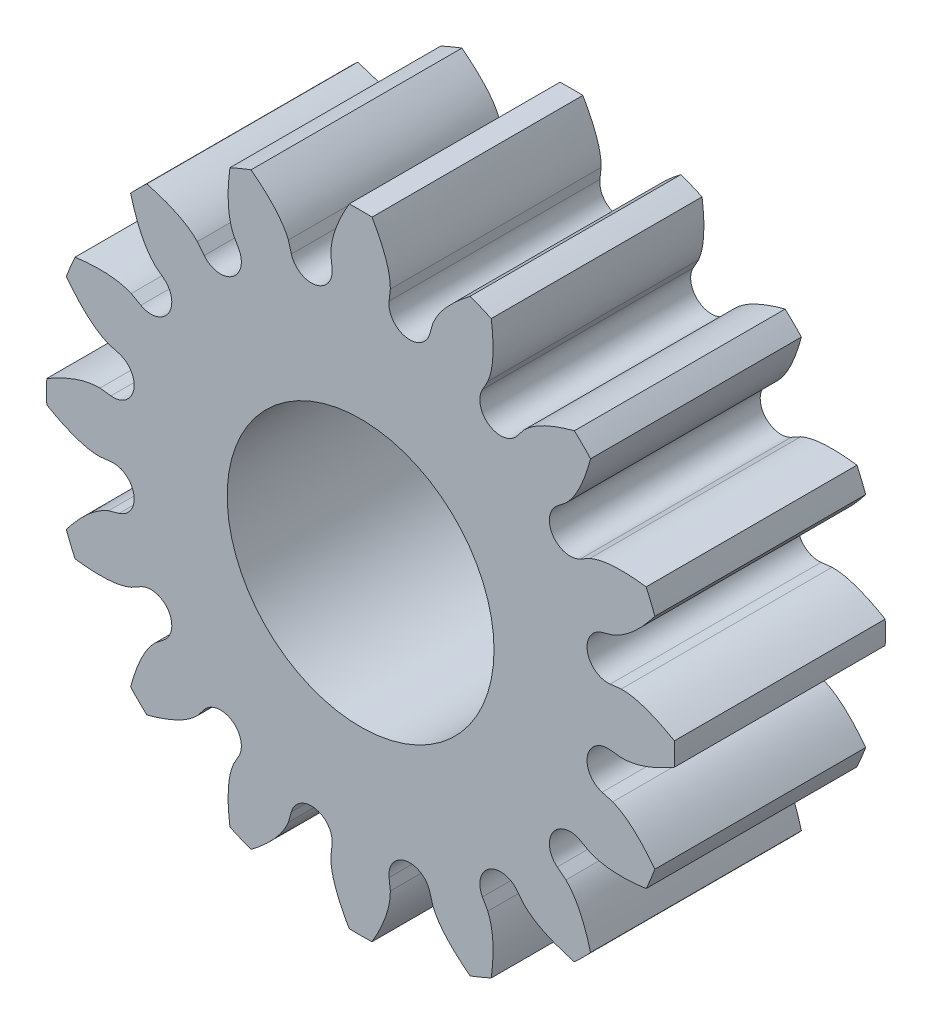
from build123d import *

# Parameters (mm, degrees)
SKETCH3_R                      = 3.302
SKETCH3_R_2                    = 1.905
BASE_DEPTH                     = 3.0099
HALF_TOOTH_DEPTH               = 3.0099
PATTERN_OF_TOOTH_COUNT         = 16
PATTERN_OF_TOOTH_COPY_1_DEPTH  = 3.0099
PATTERN_OF_TOOTH_COPY_2_DEPTH  = 3.0099
PATTERN_OF_TOOTH_COPY_3_DEPTH  = 3.0099
PATTERN_OF_TOOTH_COPY_4_DEPTH  = 3.0099
PATTERN_OF_TOOTH_COPY_5_DEPTH  = 3.0099
PATTERN_OF_TOOTH_COPY_6_DEPTH  = 3.0099
PATTERN_OF_TOOTH_COPY_7_DEPTH  = 3.0099
PATTERN_OF_TOOTH_COPY_8_DEPTH  = 3.0099
PATTERN_OF_TOOTH_COPY_9_DEPTH  = 3.0099
PATTERN_OF_TOOTH_COPY_10_DEPTH = 3.0099
PATTERN_OF_TOOTH_COPY_11_DEPTH = 3.0099
PATTERN_OF_TOOTH_COPY_12_DEPTH = 3.0099
PATTERN_OF_TOOTH_COPY_13_DEPTH = 3.0099
PATTERN_OF_TOOTH_COPY_14_DEPTH = 3.0099
PATTERN_OF_TOOTH_COPY_15_DEPTH = 3.0099


with BuildPart() as part:
    # Sketch3 → Base (new body)
    with BuildSketch(Plane.XY):
        Circle(SKETCH3_R)
        Circle(SKETCH3_R_2, mode=Mode.SUBTRACT)
    extrude(amount=BASE_DEPTH)

    # Sketch2 → Half tooth (add)
    with BuildSketch(Plane.XY):
        with BuildLine():
            Line((0, 4.4831), (0, 3.302))
            ThreePointArc((0, 3.302), (0.323652597, 3.286099967), (0.644188243, 3.238552996))
            ThreePointArc((0.644188243, 3.238552996), (0.461967142, 3.354931937), (0.406719024, 3.563968377))
            Line((0.406719024, 3.563968377), (0.424583044, 3.720505934))
            add(Edge.make_bspline(
                [(0.424583044, 3.720505934), (0.425845761, 3.803383511), (0.380146027, 4.07262239), (0.256625132, 4.316784142), (0.163284713, 4.480125413)],
                knots=[0, 0, 0, 0, 0.305960693, 1, 1, 1, 1], degree=3))
            ThreePointArc((0.163284713, 4.480125413), (0.081655902, 4.482356291), (0, 4.4831))
        make_face()
    half_tooth = extrude(amount=HALF_TOOTH_DEPTH)

    # Mirror of half tooth: Half tooth across plane
    add(half_tooth.mirror(Plane.ZY))

    # Pattern of tooth: Half tooth ×16 about axis
    pattern_of_tooth_axis = Axis((0, 0, 3.0099), (0, 0, 1))
    for i in range(1, PATTERN_OF_TOOTH_COUNT):
        add(half_tooth.rotate(pattern_of_tooth_axis, i * 360 / PATTERN_OF_TOOTH_COUNT))

    # Pattern of tooth copy 1 sketch → Pattern of tooth copy 1 (add)
    with BuildSketch(Plane(origin=(0, 0, 0), x_dir=(-0.923879533, -0.382683432, 0), z_dir=(0, 0, 1))):
        with BuildLine():
            Line((0, -4.4831), (0, -3.302))
            ThreePointArc((0, -3.302), (0.323652597, -3.286099967), (0.644188243, -3.238552996))
            ThreePointArc((0.644188243, -3.238552996), (0.461967142, -3.354931937), (0.406719024, -3.563968377))
            Line((0.406719024, -3.563968377), (0.424583044, -3.720505934))
            add(Edge.make_bspline(
                [(0.424583044, -3.720505934), (0.425845761, -3.803383511), (0.380146027, -4.07262239), (0.256625132, -4.316784142), (0.163284713, -4.480125413)],
                knots=[0, 0, 0, 0, 0.305960693, 1, 1, 1, 1], degree=3))
            ThreePointArc((0.163284713, -4.480125413), (0.081655902, -4.482356291), (0, -4.4831))
        make_face()
    extrude(amount=PATTERN_OF_TOOTH_COPY_1_DEPTH)

    # Pattern of tooth copy 2 sketch → Pattern of tooth copy 2 (add)
    with BuildSketch(Plane(origin=(0, 0, 0), x_dir=(-0.707106781, -0.707106781, 0), z_dir=(0, 0, 1))):
        with BuildLine():
            Line((0, -4.4831), (0, -3.302))
            ThreePointArc((0, -3.302), (0.323652597, -3.286099967), (0.644188243, -3.238552996))
            ThreePointArc((0.644188243, -3.238552996), (0.461967142, -3.354931937), (0.406719024, -3.563968377))
            Line((0.406719024, -3.563968377), (0.424583044, -3.720505934))
            add(Edge.make_bspline(
                [(0.424583044, -3.720505934), (0.425845761, -3.803383511), (0.380146027, -4.07262239), (0.256625132, -4.316784142), (0.163284713, -4.480125413)],
                knots=[0, 0, 0, 0, 0.305960693, 1, 1, 1, 1], degree=3))
            ThreePointArc((0.163284713, -4.480125413), (0.081655902, -4.482356291), (0, -4.4831))
        make_face()
    extrude(amount=PATTERN_OF_TOOTH_COPY_2_DEPTH)

    # Pattern of tooth copy 3 sketch → Pattern of tooth copy 3 (add)
    with BuildSketch(Plane(origin=(0, 0, 0), x_dir=(-0.382683432, -0.923879533, 0), z_dir=(0, 0, 1))):
        with BuildLine():
            Line((0, -4.4831), (0, -3.302))
            ThreePointArc((0, -3.302), (0.323652597, -3.286099967), (0.644188243, -3.238552996))
            ThreePointArc((0.644188243, -3.238552996), (0.461967142, -3.354931937), (0.406719024, -3.563968377))
            Line((0.406719024, -3.563968377), (0.424583044, -3.720505934))
            add(Edge.make_bspline(
                [(0.424583044, -3.720505934), (0.425845761, -3.803383511), (0.380146027, -4.07262239), (0.256625132, -4.316784142), (0.163284713, -4.480125413)],
                knots=[0, 0, 0, 0, 0.305960693, 1, 1, 1, 1], degree=3))
            ThreePointArc((0.163284713, -4.480125413), (0.081655902, -4.482356291), (0, -4.4831))
        make_face()
    extrude(amount=PATTERN_OF_TOOTH_COPY_3_DEPTH)

    # Pattern of tooth copy 4 sketch → Pattern of tooth copy 4 (add)
    with BuildSketch(Plane(origin=(0, 0, 0), x_dir=(0, -1, 0), z_dir=(0, 0, 1))):
        with BuildLine():
            Line((0, -4.4831), (0, -3.302))
            ThreePointArc((0, -3.302), (0.323652597, -3.286099967), (0.644188243, -3.238552996))
            ThreePointArc((0.644188243, -3.238552996), (0.461967142, -3.354931937), (0.406719024, -3.563968377))
            Line((0.406719024, -3.563968377), (0.424583044, -3.720505934))
            add(Edge.make_bspline(
                [(0.424583044, -3.720505934), (0.425845761, -3.803383511), (0.380146027, -4.07262239), (0.256625132, -4.316784142), (0.163284713, -4.480125413)],
                knots=[0, 0, 0, 0, 0.305960693, 1, 1, 1, 1], degree=3))
            ThreePointArc((0.163284713, -4.480125413), (0.081655902, -4.482356291), (0, -4.4831))
        make_face()
    extrude(amount=PATTERN_OF_TOOTH_COPY_4_DEPTH)

    # Pattern of tooth copy 5 sketch → Pattern of tooth copy 5 (add)
    with BuildSketch(Plane(origin=(0, 0, 0), x_dir=(0.382683432, -0.923879533, 0), z_dir=(0, 0, 1))):
        with BuildLine():
            Line((0, -4.4831), (0, -3.302))
            ThreePointArc((0, -3.302), (0.323652597, -3.286099967), (0.644188243, -3.238552996))
            ThreePointArc((0.644188243, -3.238552996), (0.461967142, -3.354931937), (0.406719024, -3.563968377))
            Line((0.406719024, -3.563968377), (0.424583044, -3.720505934))
            add(Edge.make_bspline(
                [(0.424583044, -3.720505934), (0.425845761, -3.803383511), (0.380146027, -4.07262239), (0.256625132, -4.316784142), (0.163284713, -4.480125413)],
                knots=[0, 0, 0, 0, 0.305960693, 1, 1, 1, 1], degree=3))
            ThreePointArc((0.163284713, -4.480125413), (0.081655902, -4.482356291), (0, -4.4831))
        make_face()
    extrude(amount=PATTERN_OF_TOOTH_COPY_5_DEPTH)

    # Pattern of tooth copy 6 sketch → Pattern of tooth copy 6 (add)
    with BuildSketch(Plane(origin=(0, 0, 0), x_dir=(0.707106781, -0.707106781, 0), z_dir=(0, 0, 1))):
        with BuildLine():
            Line((0, -4.4831), (0, -3.302))
            ThreePointArc((0, -3.302), (0.323652597, -3.286099967), (0.644188243, -3.238552996))
            ThreePointArc((0.644188243, -3.238552996), (0.461967142, -3.354931937), (0.406719024, -3.563968377))
            Line((0.406719024, -3.563968377), (0.424583044, -3.720505934))
            add(Edge.make_bspline(
                [(0.424583044, -3.720505934), (0.425845761, -3.803383511), (0.380146027, -4.07262239), (0.256625132, -4.316784142), (0.163284713, -4.480125413)],
                knots=[0, 0, 0, 0, 0.305960693, 1, 1, 1, 1], degree=3))
            ThreePointArc((0.163284713, -4.480125413), (0.081655902, -4.482356291), (0, -4.4831))
        make_face()
    extrude(amount=PATTERN_OF_TOOTH_COPY_6_DEPTH)

    # Pattern of tooth copy 7 sketch → Pattern of tooth copy 7 (add)
    with BuildSketch(Plane(origin=(0, 0, 0), x_dir=(0.923879533, -0.382683432, 0), z_dir=(0, 0, 1))):
        with BuildLine():
            Line((0, -4.4831), (0, -3.302))
            ThreePointArc((0, -3.302), (0.323652597, -3.286099967), (0.644188243, -3.238552996))
            ThreePointArc((0.644188243, -3.238552996), (0.461967142, -3.354931937), (0.406719024, -3.563968377))
            Line((0.406719024, -3.563968377), (0.424583044, -3.720505934))
            add(Edge.make_bspline(
                [(0.424583044, -3.720505934), (0.425845761, -3.803383511), (0.380146027, -4.07262239), (0.256625132, -4.316784142), (0.163284713, -4.480125413)],
                knots=[0, 0, 0, 0, 0.305960693, 1, 1, 1, 1], degree=3))
            ThreePointArc((0.163284713, -4.480125413), (0.081655902, -4.482356291), (0, -4.4831))
        make_face()
    extrude(amount=PATTERN_OF_TOOTH_COPY_7_DEPTH)

    # Pattern of tooth copy 8 sketch → Pattern of tooth copy 8 (add)
    with BuildSketch(Plane.XY):
        with BuildLine():
            Line((0, -4.4831), (0, -3.302))
            ThreePointArc((0, -3.302), (0.323652597, -3.286099967), (0.644188243, -3.238552996))
            ThreePointArc((0.644188243, -3.238552996), (0.461967142, -3.354931937), (0.406719024, -3.563968377))
            Line((0.406719024, -3.563968377), (0.424583044, -3.720505934))
            add(Edge.make_bspline(
                [(0.424583044, -3.720505934), (0.425845761, -3.803383511), (0.380146027, -4.07262239), (0.256625132, -4.316784142), (0.163284713, -4.480125413)],
                knots=[0, 0, 0, 0, 0.305960693, 1, 1, 1, 1], degree=3))
            ThreePointArc((0.163284713, -4.480125413), (0.081655902, -4.482356291), (0, -4.4831))
        make_face()
    extrude(amount=PATTERN_OF_TOOTH_COPY_8_DEPTH)

    # Pattern of tooth copy 9 sketch → Pattern of tooth copy 9 (add)
    with BuildSketch(Plane(origin=(0, 0, 0), x_dir=(0.923879533, 0.382683432, 0), z_dir=(0, 0, 1))):
        with BuildLine():
            Line((0, -4.4831), (0, -3.302))
            ThreePointArc((0, -3.302), (0.323652597, -3.286099967), (0.644188243, -3.238552996))
            ThreePointArc((0.644188243, -3.238552996), (0.461967142, -3.354931937), (0.406719024, -3.563968377))
            Line((0.406719024, -3.563968377), (0.424583044, -3.720505934))
            add(Edge.make_bspline(
                [(0.424583044, -3.720505934), (0.425845761, -3.803383511), (0.380146027, -4.07262239), (0.256625132, -4.316784142), (0.163284713, -4.480125413)],
                knots=[0, 0, 0, 0, 0.305960693, 1, 1, 1, 1], degree=3))
            ThreePointArc((0.163284713, -4.480125413), (0.081655902, -4.482356291), (0, -4.4831))
        make_face()
    extrude(amount=PATTERN_OF_TOOTH_COPY_9_DEPTH)

    # Pattern of tooth copy 10 sketch → Pattern of tooth copy 10 (add)
    with BuildSketch(Plane(origin=(0, 0, 0), x_dir=(0.707106781, 0.707106781, 0), z_dir=(0, 0, 1))):
        with BuildLine():
            Line((0, -4.4831), (0, -3.302))
            ThreePointArc((0, -3.302), (0.323652597, -3.286099967), (0.644188243, -3.238552996))
            ThreePointArc((0.644188243, -3.238552996), (0.461967142, -3.354931937), (0.406719024, -3.563968377))
            Line((0.406719024, -3.563968377), (0.424583044, -3.720505934))
            add(Edge.make_bspline(
                [(0.424583044, -3.720505934), (0.425845761, -3.803383511), (0.380146027, -4.07262239), (0.256625132, -4.316784142), (0.163284713, -4.480125413)],
                knots=[0, 0, 0, 0, 0.305960693, 1, 1, 1, 1], degree=3))
            ThreePointArc((0.163284713, -4.480125413), (0.081655902, -4.482356291), (0, -4.4831))
        make_face()
    extrude(amount=PATTERN_OF_TOOTH_COPY_10_DEPTH)

    # Pattern of tooth copy 11 sketch → Pattern of tooth copy 11 (add)
    with BuildSketch(Plane(origin=(0, 0, 0), x_dir=(0.382683432, 0.923879533, 0), z_dir=(0, 0, 1))):
        with BuildLine():
            Line((0, -4.4831), (0, -3.302))
            ThreePointArc((0, -3.302), (0.323652597, -3.286099967), (0.644188243, -3.238552996))
            ThreePointArc((0.644188243, -3.238552996), (0.461967142, -3.354931937), (0.406719024, -3.563968377))
            Line((0.406719024, -3.563968377), (0.424583044, -3.720505934))
            add(Edge.make_bspline(
                [(0.424583044, -3.720505934), (0.425845761, -3.803383511), (0.380146027, -4.07262239), (0.256625132, -4.316784142), (0.163284713, -4.480125413)],
                knots=[0, 0, 0, 0, 0.305960693, 1, 1, 1, 1], degree=3))
            ThreePointArc((0.163284713, -4.480125413), (0.081655902, -4.482356291), (0, -4.4831))
        make_face()
    extrude(amount=PATTERN_OF_TOOTH_COPY_11_DEPTH)

    # Pattern of tooth copy 12 sketch → Pattern of tooth copy 12 (add)
    with BuildSketch(Plane(origin=(0, 0, 0), x_dir=(0, 1, 0), z_dir=(0, 0, 1))):
        with BuildLine():
            Line((0, -4.4831), (0, -3.302))
            ThreePointArc((0, -3.302), (0.323652597, -3.286099967), (0.644188243, -3.238552996))
            ThreePointArc((0.644188243, -3.238552996), (0.461967142, -3.354931937), (0.406719024, -3.563968377))
            Line((0.406719024, -3.563968377), (0.424583044, -3.720505934))
            add(Edge.make_bspline(
                [(0.424583044, -3.720505934), (0.425845761, -3.803383511), (0.380146027, -4.07262239), (0.256625132, -4.316784142), (0.163284713, -4.480125413)],
                knots=[0, 0, 0, 0, 0.305960693, 1, 1, 1, 1], degree=3))
            ThreePointArc((0.163284713, -4.480125413), (0.081655902, -4.482356291), (0, -4.4831))
        make_face()
    extrude(amount=PATTERN_OF_TOOTH_COPY_12_DEPTH)

    # Pattern of tooth copy 13 sketch → Pattern of tooth copy 13 (add)
    with BuildSketch(Plane(origin=(0, 0, 0), x_dir=(-0.382683432, 0.923879533, 0), z_dir=(0, 0, 1))):
        with BuildLine():
            Line((0, -4.4831), (0, -3.302))
            ThreePointArc((0, -3.302), (0.323652597, -3.286099967), (0.644188243, -3.238552996))
            ThreePointArc((0.644188243, -3.238552996), (0.461967142, -3.354931937), (0.406719024, -3.563968377))
            Line((0.406719024, -3.563968377), (0.424583044, -3.720505934))
            add(Edge.make_bspline(
                [(0.424583044, -3.720505934), (0.425845761, -3.803383511), (0.380146027, -4.07262239), (0.256625132, -4.316784142), (0.163284713, -4.480125413)],
                knots=[0, 0, 0, 0, 0.305960693, 1, 1, 1, 1], degree=3))
            ThreePointArc((0.163284713, -4.480125413), (0.081655902, -4.482356291), (0, -4.4831))
        make_face()
    extrude(amount=PATTERN_OF_TOOTH_COPY_13_DEPTH)

    # Pattern of tooth copy 14 sketch → Pattern of tooth copy 14 (add)
    with BuildSketch(Plane(origin=(0, 0, 0), x_dir=(-0.707106781, 0.707106781, 0), z_dir=(0, 0, 1))):
        with BuildLine():
            Line((0, -4.4831), (0, -3.302))
            ThreePointArc((0, -3.302), (0.323652597, -3.286099967), (0.644188243, -3.238552996))
            ThreePointArc((0.644188243, -3.238552996), (0.461967142, -3.354931937), (0.406719024, -3.563968377))
            Line((0.406719024, -3.563968377), (0.424583044, -3.720505934))
            add(Edge.make_bspline(
                [(0.424583044, -3.720505934), (0.425845761, -3.803383511), (0.380146027, -4.07262239), (0.256625132, -4.316784142), (0.163284713, -4.480125413)],
                knots=[0, 0, 0, 0, 0.305960693, 1, 1, 1, 1], degree=3))
            ThreePointArc((0.163284713, -4.480125413), (0.081655902, -4.482356291), (0, -4.4831))
        make_face()
    extrude(amount=PATTERN_OF_TOOTH_COPY_14_DEPTH)

    # Pattern of tooth copy 15 sketch → Pattern of tooth copy 15 (add)
    with BuildSketch(Plane(origin=(0, 0, 0), x_dir=(-0.923879533, 0.382683432, 0), z_dir=(0, 0, 1))):
        with BuildLine():
            Line((0, -4.4831), (0, -3.302))
            ThreePointArc((0, -3.302), (0.323652597, -3.286099967), (0.644188243, -3.238552996))
            ThreePointArc((0.644188243, -3.238552996), (0.461967142, -3.354931937), (0.406719024, -3.563968377))
            Line((0.406719024, -3.563968377), (0.424583044, -3.720505934))
            add(Edge.make_bspline(
                [(0.424583044, -3.720505934), (0.425845761, -3.803383511), (0.380146027, -4.07262239), (0.256625132, -4.316784142), (0.163284713, -4.480125413)],
                knots=[0, 0, 0, 0, 0.305960693, 1, 1, 1, 1], degree=3))
            ThreePointArc((0.163284713, -4.480125413), (0.081655902, -4.482356291), (0, -4.4831))
        make_face()
    extrude(amount=PATTERN_OF_TOOTH_COPY_15_DEPTH)


solid = part.part
